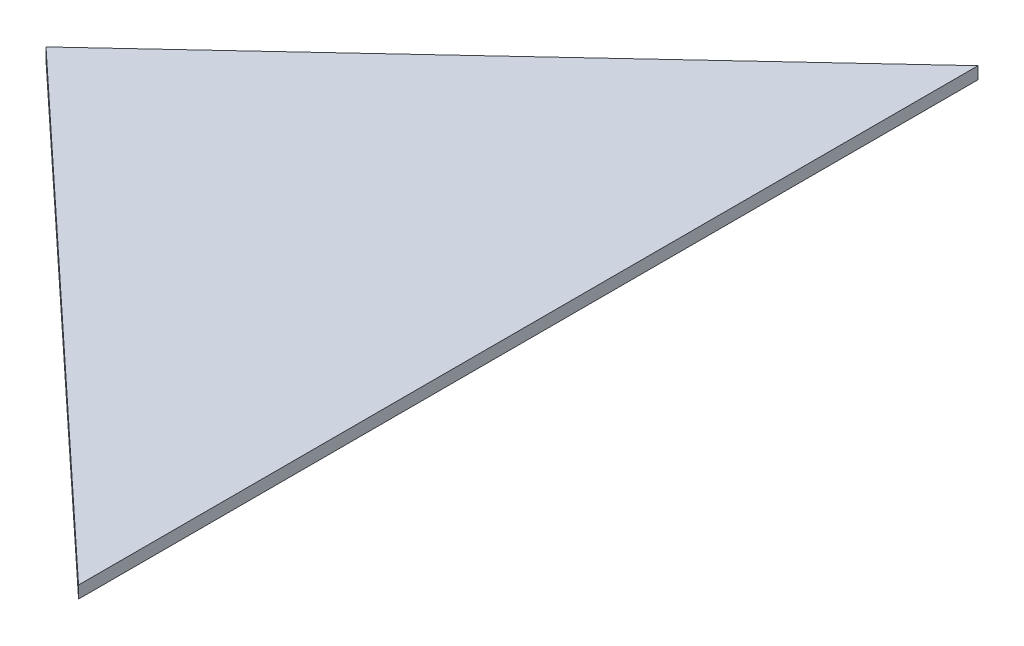
from build123d import *

# Parameters (mm, degrees)
BOSS_EXTRUDE1_DEPTH = 3.175


with BuildPart() as part:
    # Sketch1 → Boss-Extrude1 (new body)
    with BuildSketch(Plane(origin=(0, 0, 0), x_dir=(1, 0, 0), z_dir=(0, 1, 0))):
        Polygon((0, 0), (125.390592143, 116.928618833), (125.390592143, -116.928618833), align=None)
    extrude(amount=BOSS_EXTRUDE1_DEPTH)


solid = part.part
